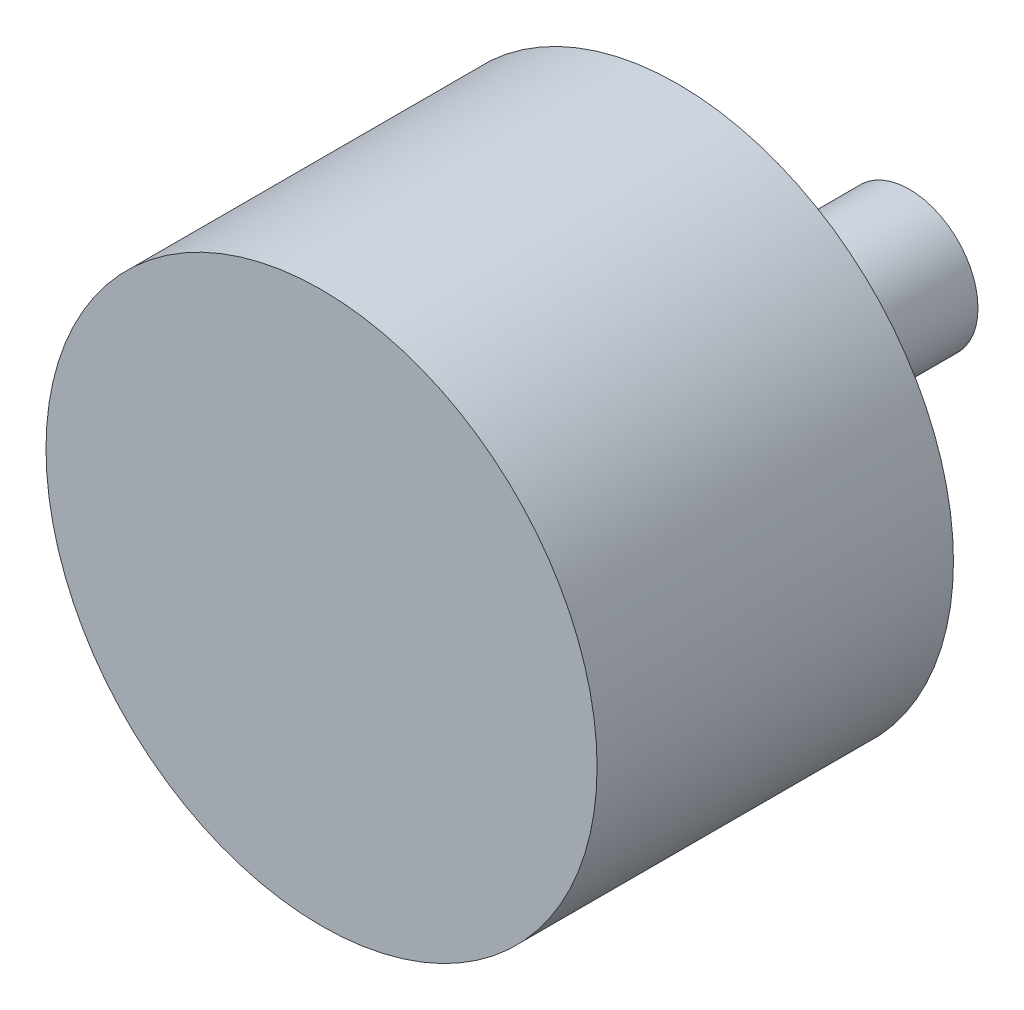
from build123d import *


with BuildPart() as part:
    # Sketch1 → Revolve1 (revolve)
    with BuildSketch(Plane(origin=(0, 0, 0), x_dir=(0, 0, -1), z_dir=(1, 0, 0))):
        Polygon((0, 0), (0, 19.05), (24.638, 19.05), (24.638, 5.461), (30.48, 5.461), (30.48, 4.74472), (40.64, 4.74472), (40.64, 0), align=None)
    revolve(axis=Axis((0, 0, 0), (0, 0, -1)))


solid = part.part
